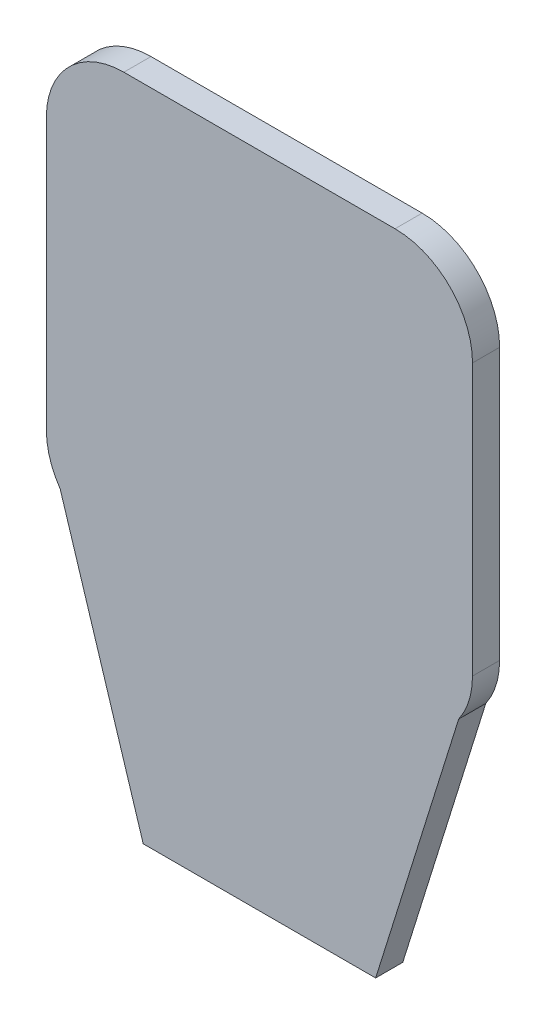
from build123d import *

# Parameters (mm, degrees)
SALIENTE_EXTRUIR1_DEPTH = 3.5


with BuildPart() as part:
    # Croquis1 → Saliente-Extruir1 (new body)
    with BuildSketch(Plane.XY):
        with BuildLine():
            Line((-16.907663566, -60.708333333), (13.092336434, -60.708333333))
            Line((13.092336434, -60.708333333), (23.808162125, -26.40922872))
            ThreePointArc((23.808162125, -26.40922872), (25.135875005, -23.695116141), (25.592336434, -20.708333333))
            Line((25.592336434, -20.708333333), (25.592336434, 14.291666667))
            ThreePointArc((25.592336434, 14.291666667), (22.663404246, 21.362734479), (15.592336434, 24.291666667))
            Line((15.592336434, 24.291666667), (-19.407663566, 24.291666667))
            ThreePointArc((-19.407663566, 24.291666667), (-26.478731378, 21.362734479), (-29.407663566, 14.291666667))
            Line((-29.407663566, 14.291666667), (-29.407663566, -20.708333333))
            ThreePointArc((-29.407663566, -20.708333333), (-28.951202137, -23.695116141), (-27.623489258, -26.40922872))
            Line((-27.623489258, -26.40922872), (-16.907663566, -60.708333333))
        make_face()
    extrude(amount=SALIENTE_EXTRUIR1_DEPTH)


solid = part.part
